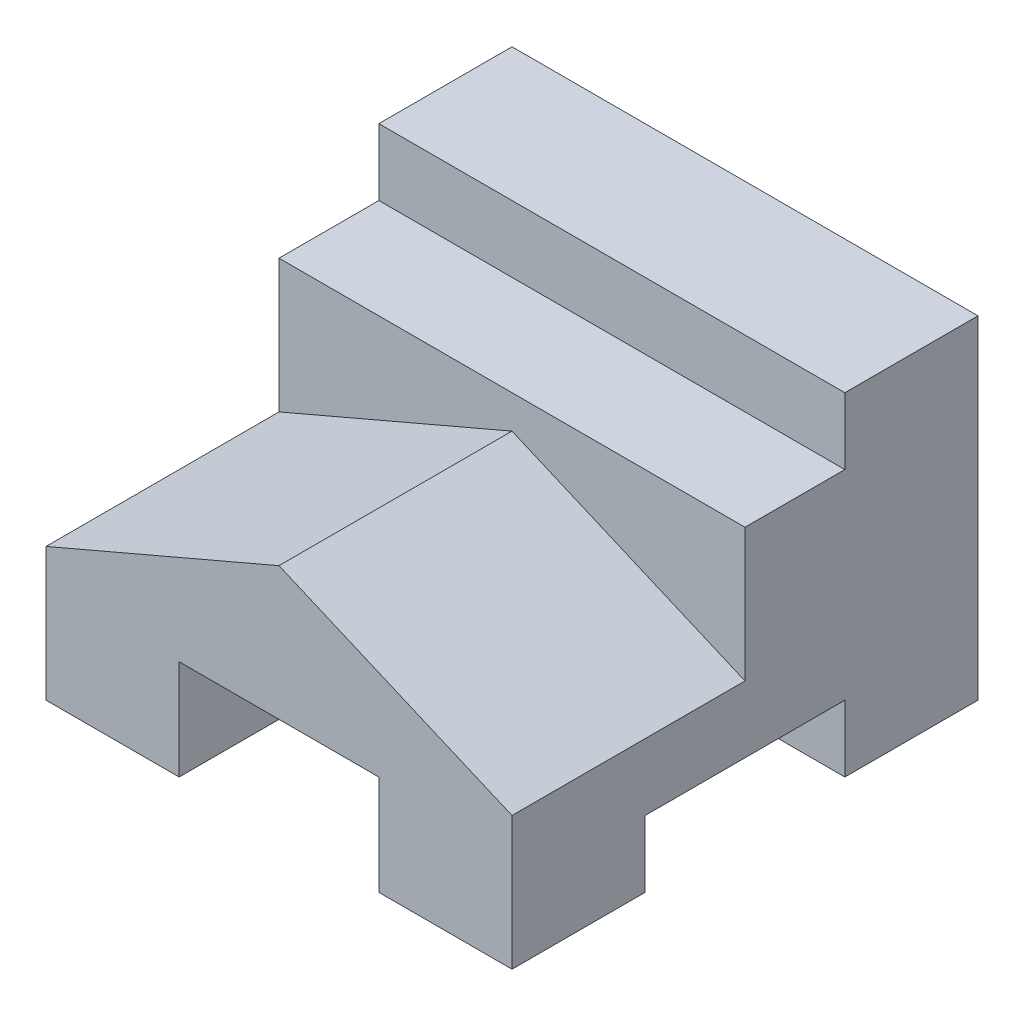
from build123d import *

# Parameters (mm, degrees)
IZIM1_W                     = 70
IZIM1_H                     = 50
Y_KSEKLIK_EKSTR_ZYON2_DEPTH = 70
IZIM2_W                     = 30
IZIM2_H                     = 10
KES_EKSTR_ZYON1_DEPTH       = 70
IZIM7_W                     = 30
IZIM7_H                     = 15
KES_EKSTR_ZYON3_DEPTH       = 70
KES_EKSTR_ZYON4_DEPTH       = 35
IZIM9_W                     = 15
IZIM9_H                     = 10
KES_EKSTR_ZYON5_DEPTH       = 70


with BuildPart() as part:
    # Çizim1 → Yükseklik-Ekstrüzyon2 (new body)
    with BuildSketch(Plane.XY):
        with Locations((3.122705421, 2.690839695)):
            Rectangle(IZIM1_W, IZIM1_H)
    extrude(amount=Y_KSEKLIK_EKSTR_ZYON2_DEPTH)

    # Çizim2 → Kes-Ekstrüzyon1 (cut)
    with BuildSketch(Plane.ZY.offset(31.877294579)):
        with Locations((35, -17.309160305)):
            Rectangle(IZIM2_W, IZIM2_H)
    extrude(amount=-KES_EKSTR_ZYON1_DEPTH, mode=Mode.SUBTRACT)

    # Çizim7 → Kes-Ekstrüzyon3 (cut)
    with BuildSketch(Plane.XY.offset(70)):
        with Locations((3.122705421, -14.809160305)):
            Rectangle(IZIM7_W, IZIM7_H)
    extrude(amount=-KES_EKSTR_ZYON3_DEPTH, mode=Mode.SUBTRACT)

    # Çizim8 → Kes-Ekstrüzyon4 (cut)
    with BuildSketch(Plane.XY.offset(70)):
        Polygon((38.122705421, -2.309160305), (3.122705421, 12.690839695), (-31.877294579, -2.309160305), (-31.877294579, 27.690839695), (38.122705421, 27.690839695), align=None)
    extrude(amount=-KES_EKSTR_ZYON4_DEPTH, mode=Mode.SUBTRACT)

    # Çizim9 → Kes-Ekstrüzyon5 (cut)
    with BuildSketch(Plane.ZY.offset(31.877294579)):
        with Locations((27.5, 22.690839695)):
            Rectangle(IZIM9_W, IZIM9_H)
    extrude(amount=-KES_EKSTR_ZYON5_DEPTH, mode=Mode.SUBTRACT)


solid = part.part
